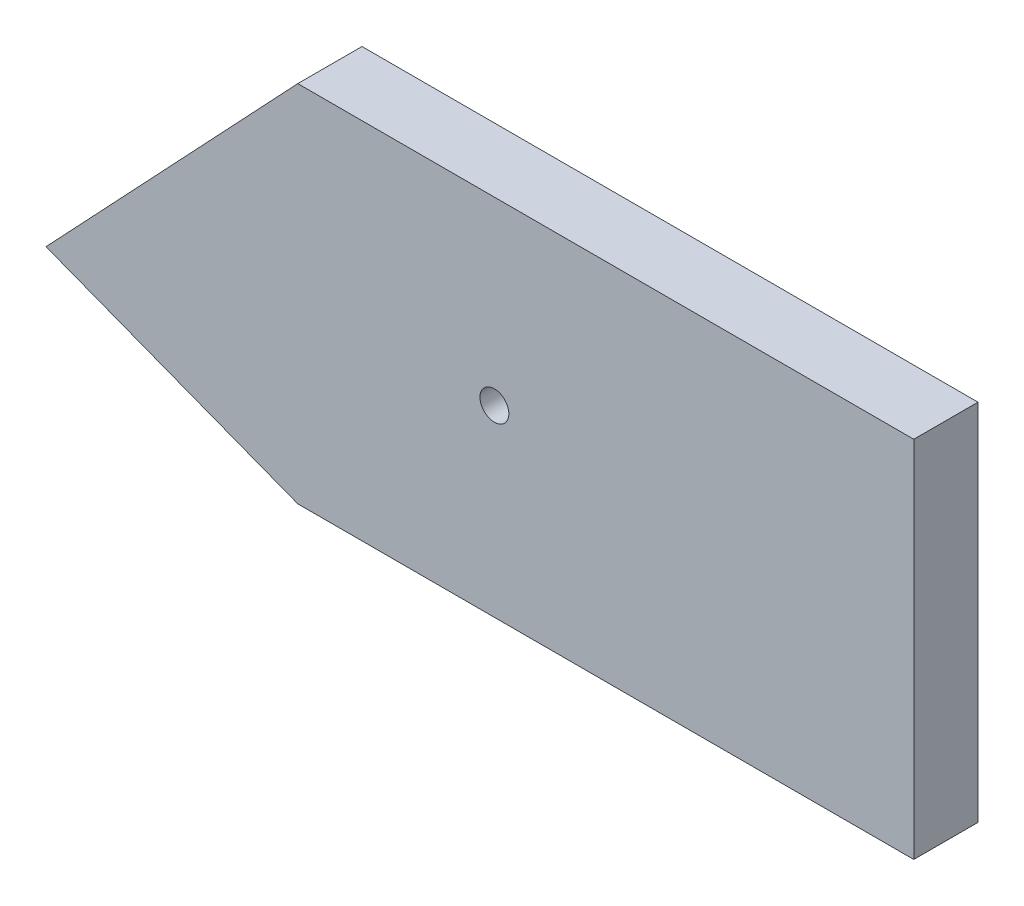
from build123d import *

# Parameters (mm, degrees)
BOSS_EXTRU_1_DEPTH = 10
D_GAGEMENT_M42_D   = 4.5


with BuildPart() as part:
    # ref externes (internes) → Boss.-Extru.1 (new body)
    with BuildSketch(Plane.XY):
        Polygon((-460.979412649, -138.268279633), (-556.886836405, -138.268279633), (-596.082218437, -179.852321051), (-556.886836405, -194.929034048), (-460.979412649, -194.929034048), align=None)
    extrude(amount=BOSS_EXTRU_1_DEPTH)

    # Dégagement M42 (through all)
    with Locations(Plane.XY.offset(10)):
        with Locations((-526.271300892, -166.364880695)):
            Hole(D_GAGEMENT_M42_D / 2)


solid = part.part
